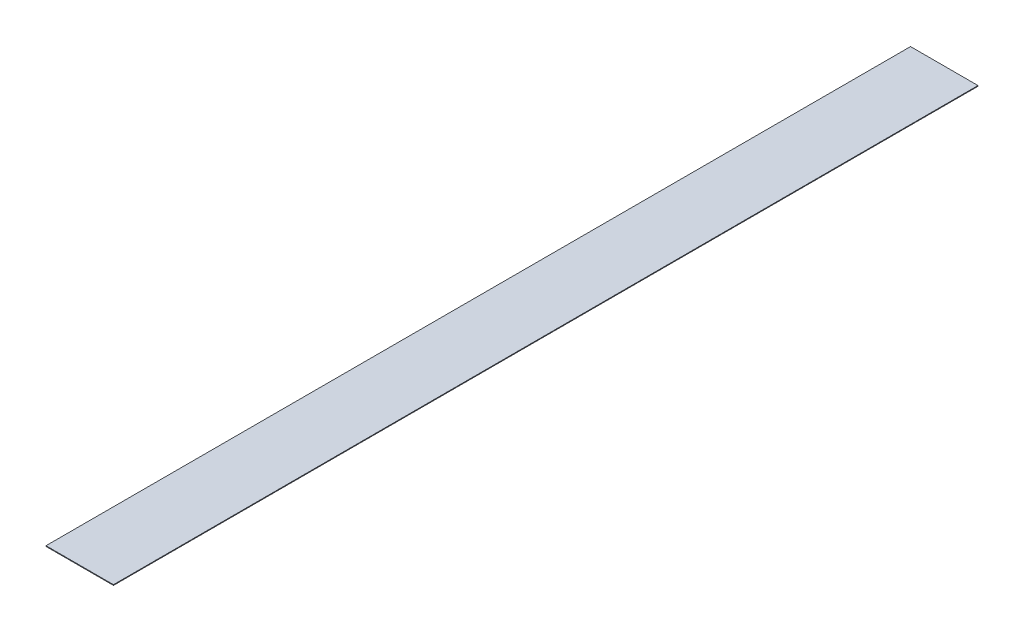
from build123d import *

# Parameters (mm, degrees)
SKETCH1_W           = 50.8
SKETCH1_H           = 650.875
BOSS_EXTRUDE1_DEPTH = 0.508


with BuildPart() as part:
    # Sketch1 → Boss-Extrude1 (new body)
    with BuildSketch(Plane(origin=(0, 0, 0), x_dir=(1, 0, 0), z_dir=(0, 1, 0))):
        with Locations((0, 325.4375)):
            Rectangle(SKETCH1_W, SKETCH1_H)
    extrude(amount=BOSS_EXTRUDE1_DEPTH)


solid = part.part
